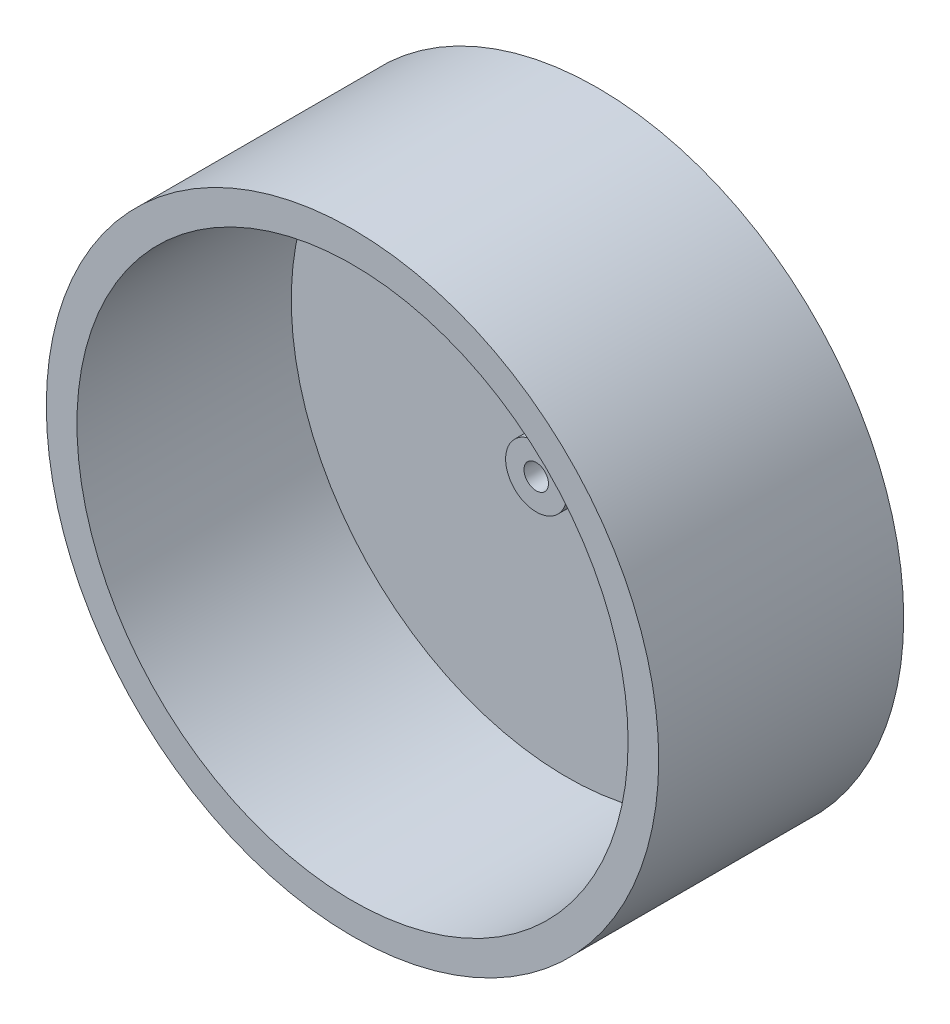
from build123d import *

# Parameters (mm, degrees)
SKETCH1_R               = 50
BOSS_EXTRUDE1_DEPTH     = 40
SHELL1_T                = -5
SKETCH2_R               = 2
CUT_EXTRUDE1_DEPTH      = 79.89866919
CUT_EXTRUDE1_DEPTH_BACK = 79.89866919
SKETCH3_R               = 5
SKETCH3_R_2             = 2
BOSS_EXTRUDE2_DEPTH     = 5


with BuildPart() as part:
    # Sketch1 → Boss-Extrude1 (new body)
    with BuildSketch(Plane.XY):
        Circle(SKETCH1_R)
    extrude(amount=BOSS_EXTRUDE1_DEPTH)

    # Shell1
    shell1_openings = [part.faces().sort_by_distance(p)[0] for p in [
        (0, 0, 40),
    ]]
    offset(amount=SHELL1_T, openings=shell1_openings, kind=Kind.INTERSECTION)

    # Sketch2 → Cut-Extrude1 (cut, two sides)
    with BuildSketch(Plane.XY.offset(5)) as cut_extrude1_sk:
        Circle(SKETCH2_R)
    extrude(amount=CUT_EXTRUDE1_DEPTH, mode=Mode.SUBTRACT)
    extrude(cut_extrude1_sk.sketch, amount=-CUT_EXTRUDE1_DEPTH_BACK, mode=Mode.SUBTRACT)

    # Sketch3 → Boss-Extrude2 (add)
    with BuildSketch(Plane.XY.offset(5)):
        Circle(SKETCH3_R)
        Circle(SKETCH3_R_2, mode=Mode.SUBTRACT)
    extrude(amount=BOSS_EXTRUDE2_DEPTH)


solid = part.part
